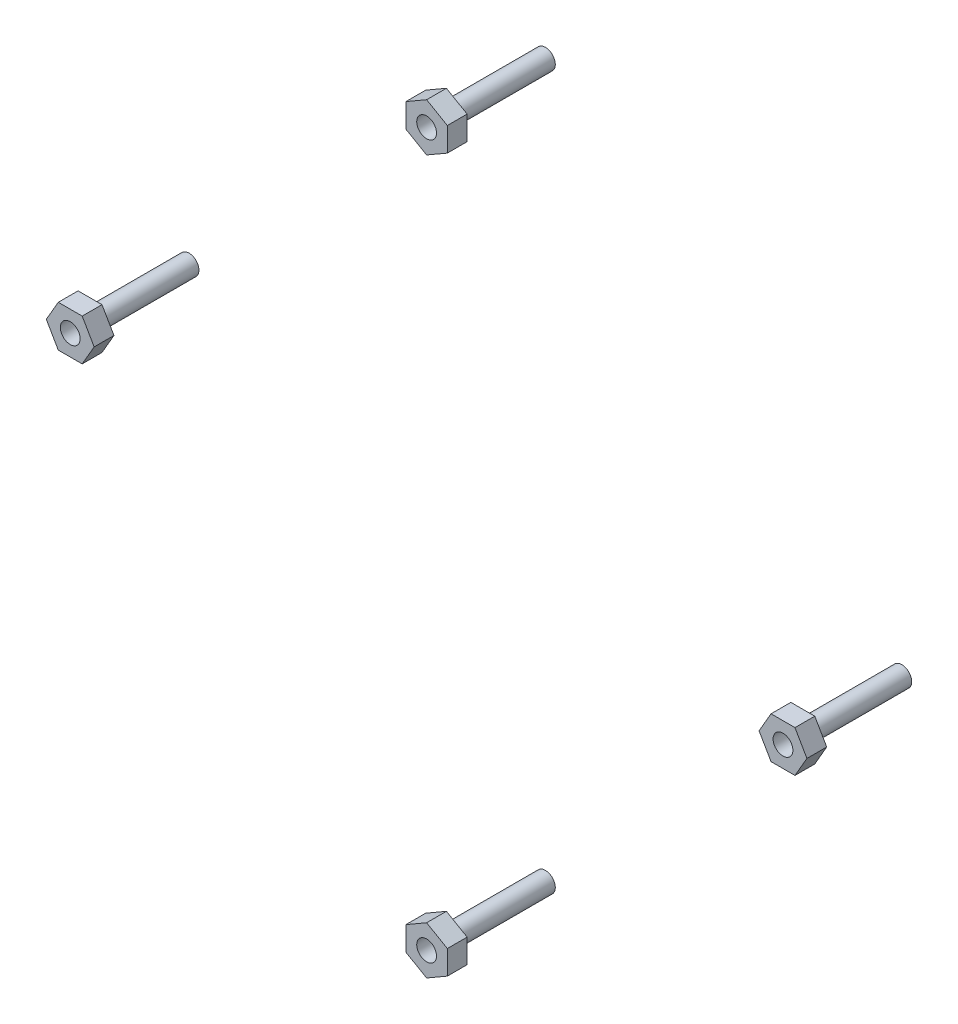
from build123d import *

# Parameters (mm, degrees)
SKETCH2_R             = 1.5
BOSS_EXTRUDE1_DEPTH   = 15
BOSS_EXTRUDE1_2_DEPTH = 15
BOSS_EXTRUDE1_3_DEPTH = 15
BOSS_EXTRUDE1_4_DEPTH = 15
SKETCH3_R             = 1.5
BOSS_EXTRUDE2_DEPTH   = 3
BOSS_EXTRUDE2_2_DEPTH = 3
BOSS_EXTRUDE2_3_DEPTH = 3
BOSS_EXTRUDE2_4_DEPTH = 3


with BuildPart() as part:
    # Sketch2 → Boss-Extrude1 (new body)
    with BuildSketch(Plane.XY):
        with Locations((0, 54)):
            Circle(SKETCH2_R)
    extrude(amount=BOSS_EXTRUDE1_DEPTH)


with BuildPart() as body_2:
    # Sketch2 → Boss-Extrude1 2 (new body)
    with BuildSketch(Plane.XY):
        with Locations((54, 0)):
            Circle(SKETCH2_R)
    extrude(amount=BOSS_EXTRUDE1_2_DEPTH)


with BuildPart() as body_3:
    # Sketch2 → Boss-Extrude1 3 (new body)
    with BuildSketch(Plane.XY):
        with Locations((0, -54)):
            Circle(SKETCH2_R)
    extrude(amount=BOSS_EXTRUDE1_3_DEPTH)


with BuildPart() as body_4:
    # Sketch2 → Boss-Extrude1 4 (new body)
    with BuildSketch(Plane.XY):
        with Locations((-54, 0)):
            Circle(SKETCH2_R)
    extrude(amount=BOSS_EXTRUDE1_4_DEPTH)


with BuildPart() as body_5:
    # Sketch3 → Boss-Extrude2 (new body)
    with BuildSketch(Plane.XY.offset(15)):
        Polygon((55.812572411, -3.139467508), (57.625144822, 0), (55.812572411, 3.139467508), (52.187427589, 3.139467508), (50.374855178, 0), (52.187427589, -3.139467508), align=None)
        with Locations((54, 0)):
            Circle(SKETCH3_R, mode=Mode.SUBTRACT)
    extrude(amount=BOSS_EXTRUDE2_DEPTH)


with BuildPart() as body_6:
    # Sketch3 → Boss-Extrude2 2 (new body)
    with BuildSketch(Plane.XY.offset(15)):
        Polygon((3.139467508, 55.812572411), (0, 57.625144822), (-3.139467508, 55.812572411), (-3.139467508, 52.187427589), (0, 50.374855178), (3.139467508, 52.187427589), align=None)
        with Locations((0, 54)):
            Circle(SKETCH3_R, mode=Mode.SUBTRACT)
    extrude(amount=BOSS_EXTRUDE2_2_DEPTH)


with BuildPart() as body_7:
    # Sketch3 → Boss-Extrude2 3 (new body)
    with BuildSketch(Plane.XY.offset(15)):
        Polygon((-3.139467508, -55.812572411), (0, -57.625144822), (3.139467508, -55.812572411), (3.139467508, -52.187427589), (0, -50.374855178), (-3.139467508, -52.187427589), align=None)
        with Locations((0, -54)):
            Circle(SKETCH3_R, mode=Mode.SUBTRACT)
    extrude(amount=BOSS_EXTRUDE2_3_DEPTH)


with BuildPart() as body_8:
    # Sketch3 → Boss-Extrude2 4 (new body)
    with BuildSketch(Plane.XY.offset(15)):
        Polygon((-55.812572411, 3.139467508), (-57.625144822, 0), (-55.812572411, -3.139467508), (-52.187427589, -3.139467508), (-50.374855178, 0), (-52.187427589, 3.139467508), align=None)
        with Locations((-54, 0)):
            Circle(SKETCH3_R, mode=Mode.SUBTRACT)
    extrude(amount=BOSS_EXTRUDE2_4_DEPTH)


solid = Compound([part.part, body_2.part, body_3.part, body_4.part, body_5.part, body_6.part, body_7.part, body_8.part])
